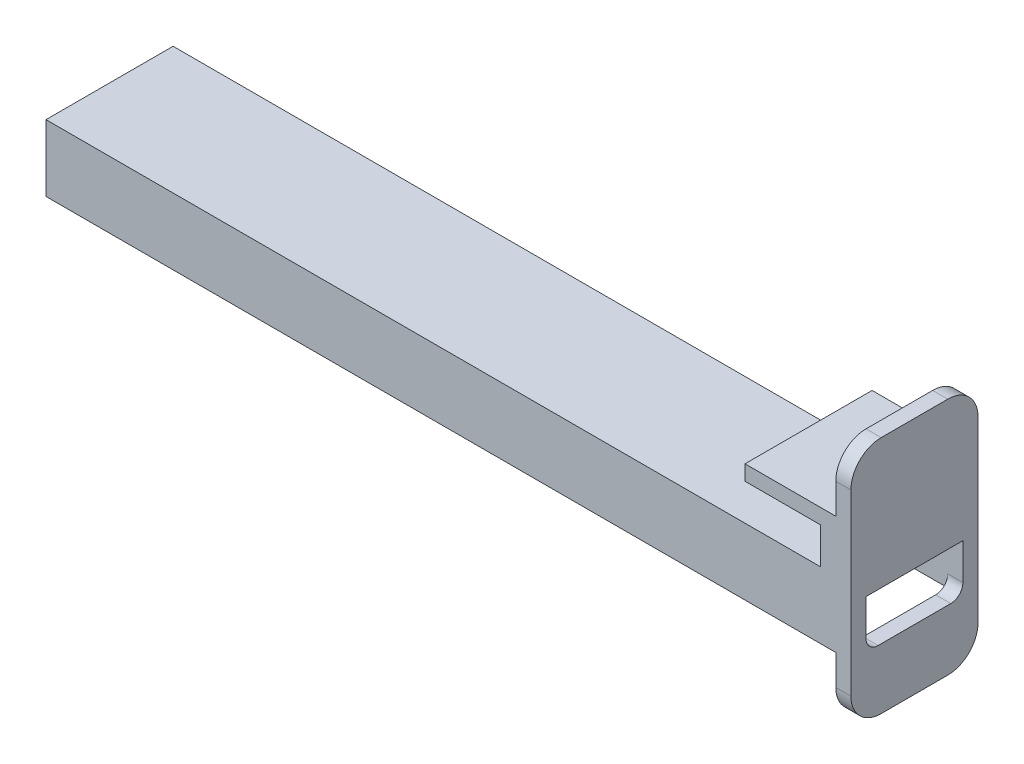
from build123d import *

# Parameters (mm, degrees)
SKETCH1_W             = 128
SKETCH1_H             = 2.5
BOSS_EXTRUDE1_DEPTH   = 8
BOSS_EXTRUDE1_2_DEPTH = 8
SKETCH2_W             = 128
SKETCH2_H             = 21
BOSS_EXTRUDE2_DEPTH   = 3
SKETCH3_W             = 21
SKETCH3_H             = 17
BOSS_EXTRUDE3_DEPTH   = 2.5
SKETCH4_W             = 15
SKETCH4_H             = 21
BOSS_EXTRUDE4_DEPTH   = 2.5
SKETCH5_W             = 21
SKETCH5_H             = 39.5
BOSS_EXTRUDE5_DEPTH   = 2.5
FILLET1_R             = 5
SKETCH6_W             = 16
SKETCH6_H             = 8
CUT_EXTRUDE1_DEPTH    = 18.5
FILLET2_R             = 2


with BuildPart() as part:
    # Sketch1 → Boss-Extrude1 (new body)
    with BuildSketch(Plane(origin=(0, 0, 0), x_dir=(1, 0, 0), z_dir=(0, 1, 0))):
        with Locations((10.384615385, 14.211538462)):
            Rectangle(SKETCH1_W, SKETCH1_H)
    extrude(amount=BOSS_EXTRUDE1_DEPTH)



with BuildPart() as body_2:
    # Sketch1 → Boss-Extrude1 2 (new body)
    with BuildSketch(Plane(origin=(0, 0, 0), x_dir=(1, 0, 0), z_dir=(0, 1, 0))):
        with Locations((10.384615385, -4.288461538)):
            Rectangle(SKETCH1_W, SKETCH1_H)
    extrude(amount=BOSS_EXTRUDE1_2_DEPTH)


with BuildPart() as part_1:
    add(part.part)

    add(body_2.part)  # Boss-Extrude2 merges body 2
    # Sketch2 → Boss-Extrude2 (add)
    with BuildSketch(Plane(origin=(0, 8, 0), x_dir=(1, 0, 0), z_dir=(0, 1, 0))):
        with Locations((10.384615385, 4.961538462)):
            Rectangle(SKETCH2_W, SKETCH2_H)
    extrude(amount=BOSS_EXTRUDE2_DEPTH)

    # Sketch3 → Boss-Extrude3 (add)
    with BuildSketch(Plane(origin=(74.384615385, 0, 0), x_dir=(0, 0, -1), z_dir=(1, 0, 0))):
        with Locations((4.961538462, 8.5)):
            Rectangle(SKETCH3_W, SKETCH3_H)
    extrude(amount=BOSS_EXTRUDE3_DEPTH)

    # Sketch4 → Boss-Extrude4 (add)
    with BuildSketch(Plane(origin=(0, 17, 0), x_dir=(1, 0, 0), z_dir=(0, 1, 0))):
        with Locations((69.384615385, 4.961538462)):
            Rectangle(SKETCH4_W, SKETCH4_H)
    extrude(amount=BOSS_EXTRUDE4_DEPTH)

    # Sketch5 → Boss-Extrude5 (add)
    with BuildSketch(Plane(origin=(76.884615385, 0, 0), x_dir=(0, 0, -1), z_dir=(1, 0, 0))):
        with Locations((4.961538462, 9.75)):
            Rectangle(SKETCH5_W, SKETCH5_H)
    extrude(amount=BOSS_EXTRUDE5_DEPTH)

    # Fillet1
    fillet1_edges = [part_1.edges().sort_by_distance(p)[0] for p in [
        (78.134615385, 29.5, 5.538461538),
        (78.134615385, -10, 5.538461538),
        (78.134615385, -10, -15.461538462),
        (78.134615385, 29.5, -15.461538462),
    ]]
    fillet(fillet1_edges, radius=FILLET1_R)

    # Sketch6 → Cut-Extrude1 (cut)
    with BuildSketch(Plane.ZY.offset(-74.384615385)):
        with Locations((-4.961538462, 4)):
            Rectangle(SKETCH6_W, SKETCH6_H)
    extrude(amount=-CUT_EXTRUDE1_DEPTH, mode=Mode.SUBTRACT)

    # Fillet2
    fillet2_edges = [part_1.edges().sort_by_distance(p)[0] for p in [
        (78.134615385, 0, 3.038461538),
        (78.134615385, 0, -12.961538462),
    ]]
    fillet(fillet2_edges, radius=FILLET2_R)


solid = part_1.part
